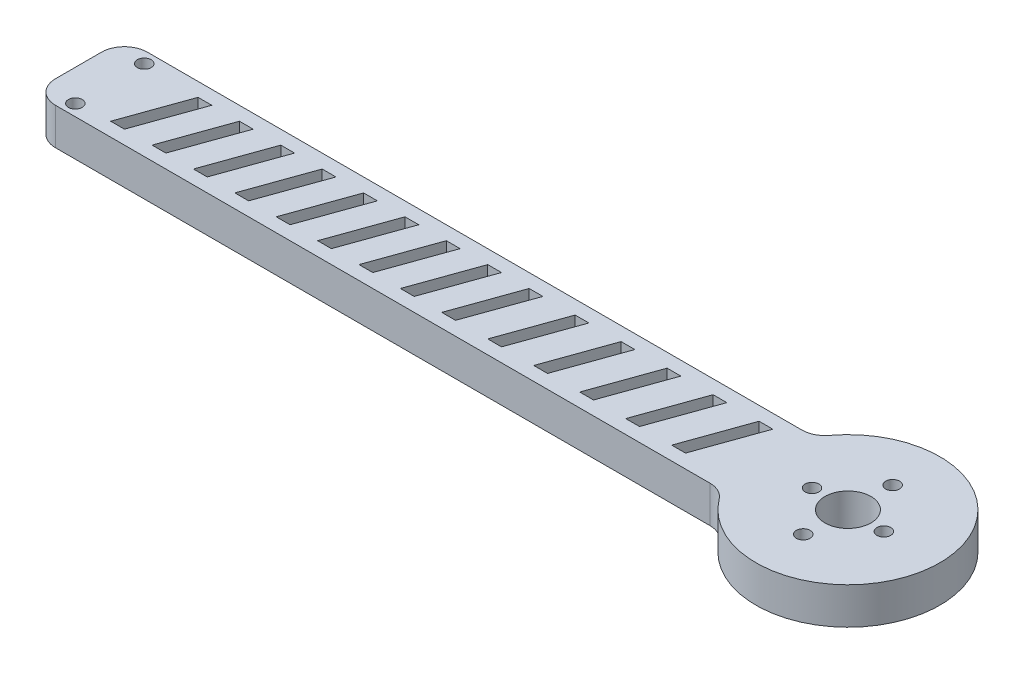
from build123d import *

# Parameters (mm, degrees)
BOSS_EXTRUDE1_DEPTH = 8
SKETCH2_R           = 1.5
SKETCH2_R_2         = 5
CUT_EXTRUDE1_DEPTH  = 25
FILLET1_R           = 5
CUT_EXTRUDE2_DEPTH  = 25
SKETCH5_R           = 1.5
CUT_EXTRUDE3_DEPTH  = 25


with BuildPart() as part:
    # Sketch1 → Boss-Extrude1 (new body)
    with BuildSketch(Plane(origin=(0, 0, 0), x_dir=(1, 0, 0), z_dir=(0, 1, 0))):
        with BuildLine():
            Line((0, 0), (150, 0))
            ThreePointArc((150, 0), (187.320508076, 10), (150, 20))
            Line((150, 20), (0, 20))
            Line((0, 20), (0, 0))
        make_face()
    extrude(amount=BOSS_EXTRUDE1_DEPTH)

    # Sketch2 → Cut-Extrude1 (cut)
    with BuildSketch(Plane(origin=(0, 8, 0), x_dir=(1, 0, 0), z_dir=(0, 1, 0))):
        with Locations((167.097723626, 0.502612618)):
            Circle(SKETCH2_R)
        with Locations((167.543292526, 19.497387382)):
            Circle(SKETCH2_R)
        with Locations((175.318307977, 9.812392042)):
            Circle(SKETCH2_R)
        with Locations((159.322708175, 10.187607958)):
            Circle(SKETCH2_R)
        with Locations((167.320508076, 10)):
            Circle(SKETCH2_R_2)
    extrude(amount=-CUT_EXTRUDE1_DEPTH, mode=Mode.SUBTRACT)

    # Fillet1
    fillet1_edges = [part.edges().sort_by_distance(p)[0] for p in [
        (0, 4, -20),
        (150, 4, -20),
        (150, 4, 0),
        (0, 4, 0),
    ]]
    fillet(fillet1_edges, radius=FILLET1_R)

    # Sketch4 → Cut-Extrude2 (cut)
    with BuildSketch(Plane(origin=(0, 8, 0), x_dir=(1, 0, 0), z_dir=(0, 1, 0))):
        Polygon((96, 3), (100.99769729, 17), (103.99769729, 17), (99, 3), align=None)
        Polygon((21.99769729, 17), (17, 3), (14, 3), (18.99769729, 17), align=None)
        Polygon((30.99769729, 17), (26, 3), (23, 3), (27.99769729, 17), align=None)
        Polygon((39.99769729, 17), (35, 3), (32, 3), (36.99769729, 17), align=None)
        Polygon((48.99769729, 17), (44, 3), (41, 3), (45.99769729, 17), align=None)
        Polygon((57.99769729, 17), (53, 3), (50, 3), (54.99769729, 17), align=None)
        Polygon((66.99769729, 17), (62, 3), (59, 3), (63.99769729, 17), align=None)
        Polygon((75.99769729, 17), (71, 3), (68, 3), (72.99769729, 17), align=None)
        Polygon((84.99769729, 17), (80, 3), (77, 3), (81.99769729, 17), align=None)
        Polygon((93.99769729, 17), (89, 3), (86, 3), (90.99769729, 17), align=None)
        Polygon((106, 3), (110.99769729, 17), (113.99769729, 17), (109, 3), align=None)
        Polygon((116, 3), (120.99769729, 17), (123.99769729, 17), (119, 3), align=None)
        Polygon((126, 3), (130.99769729, 17), (133.99769729, 17), (129, 3), align=None)
        Polygon((136, 3), (140.99769729, 17), (143.99769729, 17), (139, 3), align=None)
    extrude(amount=-CUT_EXTRUDE2_DEPTH, mode=Mode.SUBTRACT)

    # Sketch5 → Cut-Extrude3 (cut)
    with BuildSketch(Plane(origin=(0, 8, 0), x_dir=(1, 0, 0), z_dir=(0, 1, 0))):
        with Locations((6.810101414, 17.5)):
            Circle(SKETCH5_R)
        with Locations((6.810101414, 2.5)):
            Circle(SKETCH5_R)
    extrude(amount=-CUT_EXTRUDE3_DEPTH, mode=Mode.SUBTRACT)


solid = part.part
